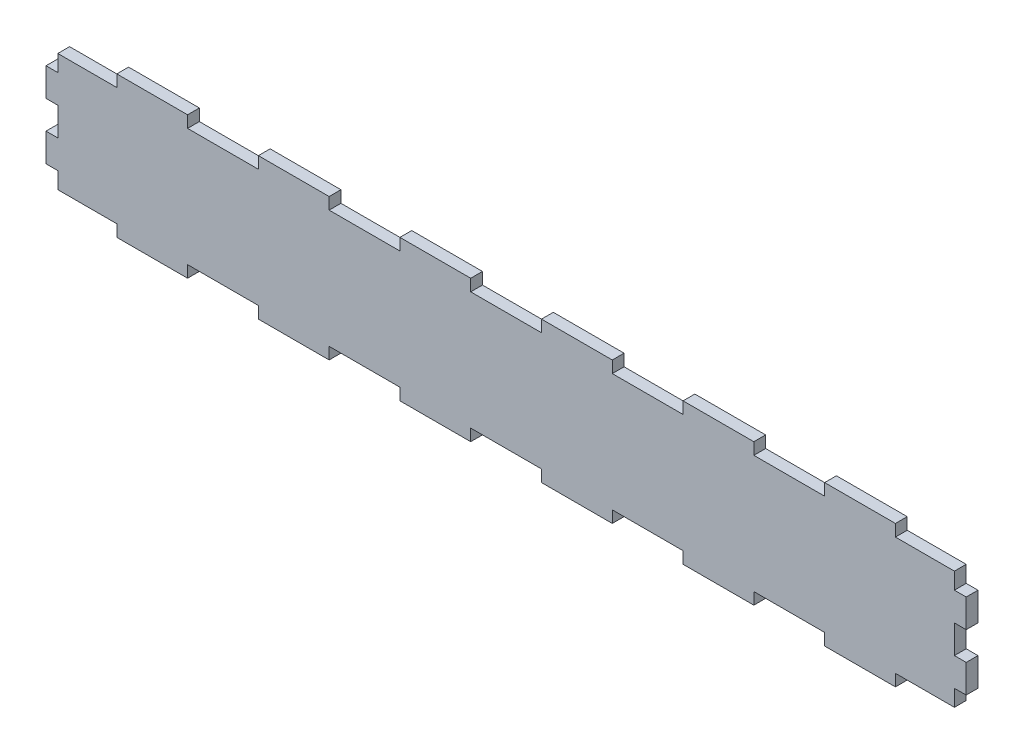
from build123d import *

# Parameters (mm, degrees)
ESQUISSE1_W                = 390
ESQUISSE1_H                = 60
BOSS_EXTRU_1_DEPTH         = 5
ESQUISSE2_W                = 30
ESQUISSE2_H                = 5
ENL_V_MAT_EXTRU_1_DEPTH    = 5
R_P_TITION_LIN_AIRE1_COUNT = 7
R_P_TITION_LIN_AIRE1_PITCH = 60
ESQUISSE3_W                = 5
ESQUISSE3_H                = 12
ENL_V_MAT_EXTRU_2_DEPTH    = 5
R_P_TITION_LIN_AIRE2_COUNT = 3
R_P_TITION_LIN_AIRE2_PITCH = 24
SYM_TRIE1_COPY_1_SKETCH_W  = 5
SYM_TRIE1_COPY_1_SKETCH_H  = 12
SYM_TRIE1_COPY_1_DEPTH     = 5
SYM_TRIE1_COPY_2_SKETCH_W  = 5
SYM_TRIE1_COPY_2_SKETCH_H  = 12
SYM_TRIE1_COPY_2_DEPTH     = 5
SYM_TRIE2_COPY_1_SKETCH_W  = 30
SYM_TRIE2_COPY_1_SKETCH_H  = 5
SYM_TRIE2_COPY_1_DEPTH     = 5
SYM_TRIE2_COPY_2_SKETCH_W  = 30
SYM_TRIE2_COPY_2_SKETCH_H  = 5
SYM_TRIE2_COPY_2_DEPTH     = 5
SYM_TRIE2_COPY_3_SKETCH_W  = 30
SYM_TRIE2_COPY_3_SKETCH_H  = 5
SYM_TRIE2_COPY_3_DEPTH     = 5
SYM_TRIE2_COPY_4_SKETCH_W  = 30
SYM_TRIE2_COPY_4_SKETCH_H  = 5
SYM_TRIE2_COPY_4_DEPTH     = 5
SYM_TRIE2_COPY_5_SKETCH_W  = 30
SYM_TRIE2_COPY_5_SKETCH_H  = 5
SYM_TRIE2_COPY_5_DEPTH     = 5
SYM_TRIE2_COPY_6_SKETCH_W  = 30
SYM_TRIE2_COPY_6_SKETCH_H  = 5
SYM_TRIE2_COPY_6_DEPTH     = 5


with BuildPart() as part:
    # Esquisse1 → Boss.-Extru.1 (new body)
    with BuildSketch(Plane.XY):
        with Locations((195, -30)):
            Rectangle(ESQUISSE1_W, ESQUISSE1_H)
    extrude(amount=BOSS_EXTRU_1_DEPTH)

    # Esquisse2 → Enlèv. mat.-Extru.1 (cut)
    with BuildSketch(Plane.XY.offset(5)):
        with Locations((15, -57.5)):
            Rectangle(ESQUISSE2_W, ESQUISSE2_H)
    enl_v_mat_extru_1 = extrude(amount=-ENL_V_MAT_EXTRU_1_DEPTH, mode=Mode.SUBTRACT)

    # Répétition linéaire1: Enlèv. mat.-Extru.1 ×7
    with Locations(*[(i * R_P_TITION_LIN_AIRE1_PITCH, 0, 0) for i in range(1, R_P_TITION_LIN_AIRE1_COUNT)]):
        add(enl_v_mat_extru_1, mode=Mode.SUBTRACT)

    # Esquisse3 → Enlèv. mat.-Extru.2 (cut)
    with BuildSketch(Plane.XY.offset(5)):
        with Locations((2.5, -54)):
            Rectangle(ESQUISSE3_W, ESQUISSE3_H)
    enl_v_mat_extru_2 = extrude(amount=-ENL_V_MAT_EXTRU_2_DEPTH, mode=Mode.SUBTRACT)

    # Répétition linéaire2: Enlèv. mat.-Extru.2 ×3
    with Locations(*[(0, i * R_P_TITION_LIN_AIRE2_PITCH, 0) for i in range(1, R_P_TITION_LIN_AIRE2_COUNT)]):
        add(enl_v_mat_extru_2, mode=Mode.SUBTRACT)

    # Symétrie1: Enlèv. mat.-Extru.2 across plane
    add(enl_v_mat_extru_2.mirror(Plane.ZY.offset(-195)), mode=Mode.SUBTRACT)

    # Symétrie1 copy 1 sketch → Symétrie1 copy 1 (cut)
    with BuildSketch(Plane(origin=(390, 24, 5), x_dir=(-1, 0, 0), z_dir=(0, 0, 1))):
        with Locations((2.5, 54)):
            Rectangle(SYM_TRIE1_COPY_1_SKETCH_W, SYM_TRIE1_COPY_1_SKETCH_H)
    extrude(amount=-SYM_TRIE1_COPY_1_DEPTH, mode=Mode.SUBTRACT)

    # Symétrie1 copy 2 sketch → Symétrie1 copy 2 (cut)
    with BuildSketch(Plane(origin=(390, 48, 5), x_dir=(-1, 0, 0), z_dir=(0, 0, 1))):
        with Locations((2.5, 54)):
            Rectangle(SYM_TRIE1_COPY_2_SKETCH_W, SYM_TRIE1_COPY_2_SKETCH_H)
    extrude(amount=-SYM_TRIE1_COPY_2_DEPTH, mode=Mode.SUBTRACT)

    # Symétrie2: Enlèv. mat.-Extru.1 across plane
    add(enl_v_mat_extru_1.mirror(Plane(origin=(0, -30, 0), x_dir=(0, 0, 1), z_dir=(0, -1, 0))), mode=Mode.SUBTRACT)

    # Symétrie2 copy 1 sketch → Symétrie2 copy 1 (cut)
    with BuildSketch(Plane(origin=(60, -60, 5), x_dir=(1, 0, 0), z_dir=(0, 0, 1))):
        with Locations((15, 57.5)):
            Rectangle(SYM_TRIE2_COPY_1_SKETCH_W, SYM_TRIE2_COPY_1_SKETCH_H)
    extrude(amount=-SYM_TRIE2_COPY_1_DEPTH, mode=Mode.SUBTRACT)

    # Symétrie2 copy 2 sketch → Symétrie2 copy 2 (cut)
    with BuildSketch(Plane(origin=(120, -60, 5), x_dir=(1, 0, 0), z_dir=(0, 0, 1))):
        with Locations((15, 57.5)):
            Rectangle(SYM_TRIE2_COPY_2_SKETCH_W, SYM_TRIE2_COPY_2_SKETCH_H)
    extrude(amount=-SYM_TRIE2_COPY_2_DEPTH, mode=Mode.SUBTRACT)

    # Symétrie2 copy 3 sketch → Symétrie2 copy 3 (cut)
    with BuildSketch(Plane(origin=(180, -60, 5), x_dir=(1, 0, 0), z_dir=(0, 0, 1))):
        with Locations((15, 57.5)):
            Rectangle(SYM_TRIE2_COPY_3_SKETCH_W, SYM_TRIE2_COPY_3_SKETCH_H)
    extrude(amount=-SYM_TRIE2_COPY_3_DEPTH, mode=Mode.SUBTRACT)

    # Symétrie2 copy 4 sketch → Symétrie2 copy 4 (cut)
    with BuildSketch(Plane(origin=(240, -60, 5), x_dir=(1, 0, 0), z_dir=(0, 0, 1))):
        with Locations((15, 57.5)):
            Rectangle(SYM_TRIE2_COPY_4_SKETCH_W, SYM_TRIE2_COPY_4_SKETCH_H)
    extrude(amount=-SYM_TRIE2_COPY_4_DEPTH, mode=Mode.SUBTRACT)

    # Symétrie2 copy 5 sketch → Symétrie2 copy 5 (cut)
    with BuildSketch(Plane(origin=(300, -60, 5), x_dir=(1, 0, 0), z_dir=(0, 0, 1))):
        with Locations((15, 57.5)):
            Rectangle(SYM_TRIE2_COPY_5_SKETCH_W, SYM_TRIE2_COPY_5_SKETCH_H)
    extrude(amount=-SYM_TRIE2_COPY_5_DEPTH, mode=Mode.SUBTRACT)

    # Symétrie2 copy 6 sketch → Symétrie2 copy 6 (cut)
    with BuildSketch(Plane(origin=(360, -60, 5), x_dir=(1, 0, 0), z_dir=(0, 0, 1))):
        with Locations((15, 57.5)):
            Rectangle(SYM_TRIE2_COPY_6_SKETCH_W, SYM_TRIE2_COPY_6_SKETCH_H)
    extrude(amount=-SYM_TRIE2_COPY_6_DEPTH, mode=Mode.SUBTRACT)


solid = part.part
